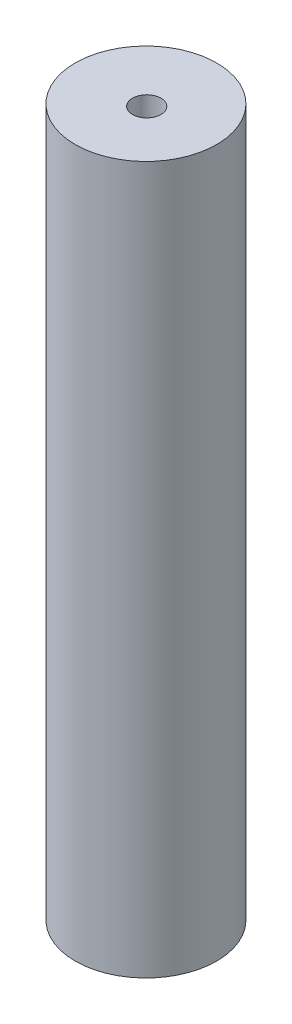
from build123d import *

# Parameters (mm, degrees)
SKETCH2_R           = 12.7
BOSS_EXTRUDE1_DEPTH = 127


with BuildPart() as part:
    # Sketch2 → Boss-Extrude1 (new body)
    with BuildSketch(Plane(origin=(0, 0, 0), x_dir=(1, 0, 0), z_dir=(0, 1, 0))):
        Circle(SKETCH2_R)
    extrude(amount=BOSS_EXTRUDE1_DEPTH)

    # Sketch4 → 1/4-20 Tapped Hole1 (revolve, cut)
    with BuildSketch(Plane(origin=(0.473892963, 127, 0.332854466), x_dir=(0, 0, 1), z_dir=(1, 0, 0))):
        Polygon((0, 0), (0, 33.283816902), (2.5527, 31.75), (2.5527, 0), align=None)
    f_1_4_20_tapped_hole1 = revolve(axis=Axis((0.473892963, 133.35, 0.332854466), (0, -1, 0)), mode=Mode.SUBTRACT)

    # Mirror1: 1/4-20 Tapped Hole1 across plane
    add(f_1_4_20_tapped_hole1.mirror(Plane.ZX.offset(63.5)), mode=Mode.SUBTRACT)


solid = part.part
